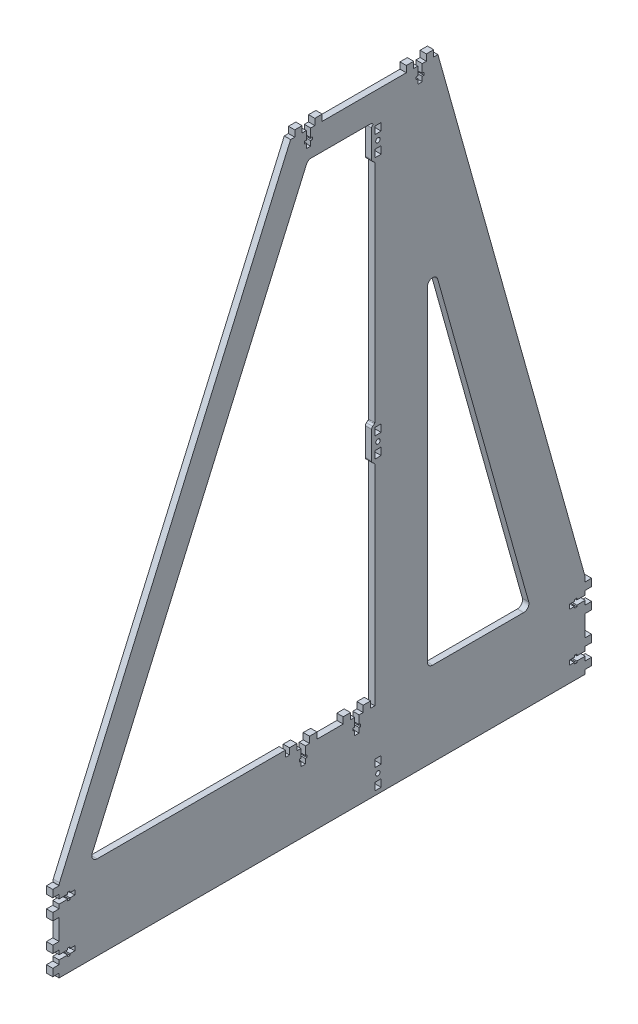
from build123d import *

# Parameters (mm, degrees)
EXTRUDE_869_DEPTH     = 6
SKETCH_2_W            = 7
SKETCH_2_H            = 6
EXTRUDE_2_DEPTH       = 6
CUT_EXTRUDE_1_DEPTH   = 7
SKETCH_21_W           = 7
SKETCH_21_H           = 6
EXTRUDE_21_DEPTH      = 6
CUT_EXTRUDE_11_DEPTH  = 7
SKETCH_22_W           = 7
SKETCH_22_H           = 6
EXTRUDE_22_DEPTH      = 6
SKETCH_23_W           = 7
SKETCH_23_H           = 6
EXTRUDE_23_DEPTH      = 6
SKETCH_24_W           = 7
SKETCH_24_H           = 6
EXTRUDE_24_DEPTH      = 6
CUT_EXTRUDE_14_DEPTH  = 7
SKETCH_25_W           = 7
SKETCH_25_H           = 6
EXTRUDE_25_DEPTH      = 6
CUT_EXTRUDE_15_DEPTH  = 7
SKETCH_26_W           = 7
SKETCH_26_H           = 6
EXTRUDE_26_DEPTH      = 6
SKETCH_27_W           = 7
SKETCH_27_H           = 6
EXTRUDE_27_DEPTH      = 6
SKETCH_28_W           = 7
SKETCH_28_H           = 6
EXTRUDE_28_DEPTH      = 6
CUT_EXTRUDE_18_DEPTH  = 7
SKETCH_29_W           = 7
SKETCH_29_H           = 6
EXTRUDE_29_DEPTH      = 6
CUT_EXTRUDE_19_DEPTH  = 7
SKETCH_210_W          = 7
SKETCH_210_H          = 6
EXTRUDE_210_DEPTH     = 6
SKETCH_211_W          = 7
SKETCH_211_H          = 6
EXTRUDE_211_DEPTH     = 6
SKETCH_312_R          = 2.1
SKETCH_312_W          = 7
SKETCH_312_H          = 6
CUT_EXTRUDE_112_DEPTH = 7
EXTRUDE_212_DEPTH     = 6
SKETCH_313_R          = 2.1
SKETCH_313_W          = 7
SKETCH_313_H          = 6
CUT_EXTRUDE_113_DEPTH = 7
EXTRUDE_213_DEPTH     = 6
EXTRUDE_214_DEPTH     = 6
SKETCH_315_R          = 2.1
SKETCH_315_W          = 7
SKETCH_315_H          = 6
CUT_EXTRUDE_115_DEPTH = 7
EXTRUDE_215_DEPTH     = 6
SKETCH_216_W          = 7
SKETCH_216_H          = 6
EXTRUDE_216_DEPTH     = 6
CUT_EXTRUDE_118_DEPTH = 7
SKETCH_218_W          = 7
SKETCH_218_H          = 6
EXTRUDE_219_DEPTH     = 6
CUT_EXTRUDE_121_DEPTH = 7


with BuildPart() as part:
    # Sketch 860 → Extrude 869 (new body)
    with BuildSketch(Plane(origin=(0, 0, 0), x_dir=(0, 0, -1), z_dir=(1, 0, 0))):
        with BuildLine():
            Line((-623.889101777, -244.379195599), (-123.889101777, -244.379195599))
            Line((-123.889101777, -244.379195599), (-123.889101777, -165.065988436))
            ThreePointArc((-123.889101777, -165.065988436), (-123.935613083, -164.385584326), (-124.074281679, -163.717838809))
            Line((-124.074281679, -163.717838809), (-263.889101777, 335.620804401))
            Line((-263.889101777, 335.620804401), (-313.803205915, 335.620804401))
            Line((-313.803205915, 335.620804401), (-403.889101777, 335.620804401))
            Line((-403.889101777, 335.620804401), (-623.469708885, -166.155300097))
            ThreePointArc((-623.469708885, -166.155300097), (-623.783130564, -167.135850443), (-623.889101777, -168.159804657))
            Line((-623.889101777, -168.159804657), (-623.889101777, -244.379195599))
        make_face()
        with BuildLine():
            Line((-323.889101777, 305.620804401), (-323.889101777, -164.379195599))
            Line((-323.889101777, -164.379195599), (-323.889101777, -170.379195599))
            Line((-323.889101777, -170.379195599), (-408.878708178, -170.379195599))
            Line((-408.878708178, -170.379195599), (-408.878708178, -164.379195599))
            Line((-408.878708178, -164.379195599), (-587.757688941, -164.379195599))
            ThreePointArc((-587.757688941, -164.379195599), (-591.942334851, -162.115751574), (-592.338296048, -157.37469104))
            Line((-592.338296048, -157.37469104), (-388.851160272, 307.62530896))
            ThreePointArc((-388.851160272, 307.62530896), (-387.007109139, 309.805450311), (-384.270553165, 310.620804401))
            Line((-384.270553165, 310.620804401), (-328.889101777, 310.620804401))
            ThreePointArc((-328.889101777, 310.620804401), (-325.353567872, 309.156338307), (-323.889101777, 305.620804401))
        make_face(mode=Mode.SUBTRACT)
        with BuildLine():
            Line((-268.889101777, -164.379195599), (-182.404423715, -164.379195599))
            ThreePointArc((-182.404423715, -164.379195599), (-178.420659908, -162.400722685), (-177.589603616, -158.031045972))
            Line((-177.589603616, -158.031045972), (-264.074281679, 150.842804252))
            ThreePointArc((-264.074281679, 150.842804252), (-269.569505888, 154.448143319), (-273.889101777, 149.494654625))
            Line((-273.889101777, 149.494654625), (-273.889101777, -159.379195599))
            ThreePointArc((-273.889101777, -159.379195599), (-272.424635683, -162.914729505), (-268.889101777, -164.379195599))
        make_face(mode=Mode.SUBTRACT)
    extrude(amount=EXTRUDE_869_DEPTH)

    # Эскиз2 → Бобышка-Вытянуть2 (add)
    with BuildSketch(Plane(origin=(6, 285.620804401, 386.889101777), x_dir=(0, 0, -1), z_dir=(1, 0, 0))):
        with Locations((-9.531849908, 53)):
            Rectangle(SKETCH_2_W, SKETCH_2_H)
        with Locations((9.531849908, 53)):
            Rectangle(SKETCH_2_W, SKETCH_2_H)
    extrude(amount=-EXTRUDE_2_DEPTH)

    # Эскиз3 → Вырез-Вытянуть1 (cut, through all)
    with BuildSketch(Plane(origin=(6, 285.620804401, 386.889101777), x_dir=(0, 0, -1), z_dir=(1, 0, 0))):
        Polygon((-2.1, 42), (-3.6, 42), (-3.6, 39.6), (-2.1, 39.6), (-2.1, 35), (2.1, 35), (2.1, 39.6), (3.6, 39.6), (3.6, 42), (2.1, 42), (2.1, 50), (-2.1, 50), align=None)
    extrude(amount=-CUT_EXTRUDE_1_DEPTH, mode=Mode.SUBTRACT)

    # Эскиз21 → Бобышка-Вытянуть21 (add)
    with BuildSketch(Plane(origin=(6, 285.620804401, 280.889101778), x_dir=(0, 0, -1), z_dir=(1, 0, 0))):
        with Locations((-9.531849908, 53)):
            Rectangle(SKETCH_21_W, SKETCH_21_H)
        with Locations((9.531849908, 53)):
            Rectangle(SKETCH_21_W, SKETCH_21_H)
    extrude(amount=-EXTRUDE_21_DEPTH)

    # Эскиз31 → Вырез-Вытянуть11 (cut, through all)
    with BuildSketch(Plane(origin=(6, 285.620804401, 280.889101778), x_dir=(0, 0, -1), z_dir=(1, 0, 0))):
        Polygon((-2.1, 42), (-3.6, 42), (-3.6, 39.6), (-2.1, 39.6), (-2.1, 35), (2.1, 35), (2.1, 39.6), (3.6, 39.6), (3.6, 42), (2.1, 42), (2.1, 50), (-2.1, 50), align=None)
    extrude(amount=-CUT_EXTRUDE_11_DEPTH, mode=Mode.SUBTRACT)

    # Эскиз22 → Бобышка-Вытянуть22 (add)
    with BuildSketch(Plane(origin=(0, 285.620804401, 386.889101777), x_dir=(0, 0, 1), z_dir=(-1, 0, 0))):
        with Locations((-9.531849908, 53)):
            Rectangle(SKETCH_22_W, SKETCH_22_H)
        with Locations((9.531849908, 53)):
            Rectangle(SKETCH_22_W, SKETCH_22_H)
    extrude(amount=-EXTRUDE_22_DEPTH)

    # Эскиз23 → Бобышка-Вытянуть23 (add)
    with BuildSketch(Plane(origin=(0, 285.620804401, 280.889101777), x_dir=(0, 0, 1), z_dir=(-1, 0, 0))):
        with Locations((-9.531849908, 53)):
            Rectangle(SKETCH_23_W, SKETCH_23_H)
        with Locations((9.531849908, 53)):
            Rectangle(SKETCH_23_W, SKETCH_23_H)
    extrude(amount=-EXTRUDE_23_DEPTH)

    # Эскиз24 → Бобышка-Вытянуть24 (add)
    with BuildSketch(Plane(origin=(0, -181.461538462, 573.889101777), x_dir=(0, -1, 0), z_dir=(-1, 0, 0))):
        with Locations((-9.531849908, 53)):
            Rectangle(SKETCH_24_W, SKETCH_24_H)
        with Locations((9.531849908, 53)):
            Rectangle(SKETCH_24_W, SKETCH_24_H)
    extrude(amount=-EXTRUDE_24_DEPTH)

    # Эскиз34 → Вырез-Вытянуть14 (cut, through all)
    with BuildSketch(Plane(origin=(0, -181.461538462, 573.889101777), x_dir=(0, -1, 0), z_dir=(-1, 0, 0))):
        Polygon((-2.1, 42), (-3.6, 42), (-3.6, 39.6), (-2.1, 39.6), (-2.1, 35), (2.1, 35), (2.1, 39.6), (3.6, 39.6), (3.6, 42), (2.1, 42), (2.1, 50), (-2.1, 50), align=None)
    extrude(amount=-CUT_EXTRUDE_14_DEPTH, mode=Mode.SUBTRACT)

    # Эскиз25 → Бобышка-Вытянуть25 (add)
    with BuildSketch(Plane(origin=(0, -227.379195599, 573.889101777), x_dir=(0, -1, 0), z_dir=(-1, 0, 0))):
        with Locations((-9.531849908, 53)):
            Rectangle(SKETCH_25_W, SKETCH_25_H)
        with Locations((9.531849908, 53)):
            Rectangle(SKETCH_25_W, SKETCH_25_H)
    extrude(amount=-EXTRUDE_25_DEPTH)

    # Эскиз35 → Вырез-Вытянуть15 (cut, through all)
    with BuildSketch(Plane(origin=(0, -227.379195599, 573.889101777), x_dir=(0, -1, 0), z_dir=(-1, 0, 0))):
        Polygon((-2.1, 42), (-3.6, 42), (-3.6, 39.6), (-2.1, 39.6), (-2.1, 35), (2.1, 35), (2.1, 39.6), (3.6, 39.6), (3.6, 42), (2.1, 42), (2.1, 50), (-2.1, 50), align=None)
    extrude(amount=-CUT_EXTRUDE_15_DEPTH, mode=Mode.SUBTRACT)

    # Эскиз26 → Бобышка-Вытянуть26 (add)
    with BuildSketch(Plane(origin=(6, -181.461538462, 573.889101777), x_dir=(0, 1, 0), z_dir=(1, 0, 0))):
        with Locations((-9.531849908, 53)):
            Rectangle(SKETCH_26_W, SKETCH_26_H)
        with Locations((9.531849908, 53)):
            Rectangle(SKETCH_26_W, SKETCH_26_H)
    extrude(amount=-EXTRUDE_26_DEPTH)

    # Эскиз27 → Бобышка-Вытянуть27 (add)
    with BuildSketch(Plane(origin=(6, -227.379195599, 573.889101777), x_dir=(0, 1, 0), z_dir=(1, 0, 0))):
        with Locations((-9.531849908, 53)):
            Rectangle(SKETCH_27_W, SKETCH_27_H)
        with Locations((9.531849908, 53)):
            Rectangle(SKETCH_27_W, SKETCH_27_H)
    extrude(amount=-EXTRUDE_27_DEPTH)

    # Эскиз28 → Бобышка-Вытянуть28 (add)
    with BuildSketch(Plane(origin=(6, -181.379195599, 173.889101777), x_dir=(0, -1, 0), z_dir=(1, 0, 0))):
        with Locations((-9.531849908, 53)):
            Rectangle(SKETCH_28_W, SKETCH_28_H)
        with Locations((9.531849908, 53)):
            Rectangle(SKETCH_28_W, SKETCH_28_H)
    extrude(amount=-EXTRUDE_28_DEPTH)

    # Эскиз38 → Вырез-Вытянуть18 (cut, through all)
    with BuildSketch(Plane(origin=(6, -181.379195599, 173.889101777), x_dir=(0, -1, 0), z_dir=(1, 0, 0))):
        Polygon((-2.1, 42), (-3.6, 42), (-3.6, 39.6), (-2.1, 39.6), (-2.1, 35), (2.1, 35), (2.1, 39.6), (3.6, 39.6), (3.6, 42), (2.1, 42), (2.1, 50), (-2.1, 50), align=None)
    extrude(amount=-CUT_EXTRUDE_18_DEPTH, mode=Mode.SUBTRACT)

    # Эскиз29 → Бобышка-Вытянуть29 (add)
    with BuildSketch(Plane(origin=(6, -227.379195599, 173.889101777), x_dir=(0, -1, 0), z_dir=(1, 0, 0))):
        with Locations((-9.531849908, 53)):
            Rectangle(SKETCH_29_W, SKETCH_29_H)
        with Locations((9.531849908, 53)):
            Rectangle(SKETCH_29_W, SKETCH_29_H)
    extrude(amount=-EXTRUDE_29_DEPTH)

    # Эскиз39 → Вырез-Вытянуть19 (cut, through all)
    with BuildSketch(Plane(origin=(6, -227.379195599, 173.889101777), x_dir=(0, -1, 0), z_dir=(1, 0, 0))):
        Polygon((-2.1, 42), (-3.6, 42), (-3.6, 39.6), (-2.1, 39.6), (-2.1, 35), (2.1, 35), (2.1, 39.6), (3.6, 39.6), (3.6, 42), (2.1, 42), (2.1, 50), (-2.1, 50), align=None)
    extrude(amount=-CUT_EXTRUDE_19_DEPTH, mode=Mode.SUBTRACT)

    # Эскиз210 → Бобышка-Вытянуть210 (add)
    with BuildSketch(Plane(origin=(0, -181.379195599, 173.889101777), x_dir=(0, 1, 0), z_dir=(-1, 0, 0))):
        with Locations((-9.531849908, 53)):
            Rectangle(SKETCH_210_W, SKETCH_210_H)
        with Locations((9.531849908, 53)):
            Rectangle(SKETCH_210_W, SKETCH_210_H)
    extrude(amount=-EXTRUDE_210_DEPTH)

    # Эскиз211 → Бобышка-Вытянуть211 (add)
    with BuildSketch(Plane(origin=(0, -227.379195599, 173.889101777), x_dir=(0, 1, 0), z_dir=(-1, 0, 0))):
        with Locations((-9.531849908, 53)):
            Rectangle(SKETCH_211_W, SKETCH_211_H)
        with Locations((9.531849908, 53)):
            Rectangle(SKETCH_211_W, SKETCH_211_H)
    extrude(amount=-EXTRUDE_211_DEPTH)

    # Эскиз312 → Вырез-Вытянуть112 (cut, through all)
    with BuildSketch(Plane(origin=(6, -227.379195599, 273.889101777), x_dir=(0, 1, 0), z_dir=(1, 0, 0))):
        with Locations((0, 47)):
            Circle(SKETCH_312_R)
        with Locations((9.531849908, 47)):
            Rectangle(SKETCH_312_W, SKETCH_312_H)
        with Locations((-9.531849908, 47)):
            Rectangle(SKETCH_312_W, SKETCH_312_H)
    extrude(amount=-CUT_EXTRUDE_112_DEPTH, mode=Mode.SUBTRACT)

    # Эскиз212 → Бобышка-Вытянуть212 (add)
    with BuildSketch(Plane(origin=(0, 45.620804401, 273.889101777), x_dir=(0, 1, 0), z_dir=(1, 0, 0))):
        with BuildLine():
            Line((13, 53), (-13, 53))
            ThreePointArc((-13, 53), (-14.118033989, 52.736067977), (-15, 52))
            Line((-15, 52), (-16.2, 50.4))
            ThreePointArc((-16.2, 50.4), (-16.552786405, 50.105572809), (-17, 50))
            Line((-17, 50), (17, 50))
            ThreePointArc((17, 50), (16.552786405, 50.105572809), (16.2, 50.4))
            Line((16.2, 50.4), (15, 52))
            ThreePointArc((15, 52), (14.118033989, 52.736067977), (13, 53))
        make_face()
    extrude(amount=EXTRUDE_212_DEPTH)

    # Эскиз313 → Вырез-Вытянуть113 (cut, through all)
    with BuildSketch(Plane(origin=(6, 45.620804401, 273.889101777), x_dir=(0, 1, 0), z_dir=(1, 0, 0))):
        with Locations((0, 47)):
            Circle(SKETCH_313_R)
        with Locations((9.531849908, 47)):
            Rectangle(SKETCH_313_W, SKETCH_313_H)
        with Locations((-9.531849908, 47)):
            Rectangle(SKETCH_313_W, SKETCH_313_H)
    extrude(amount=-CUT_EXTRUDE_113_DEPTH, mode=Mode.SUBTRACT)

    # Эскиз213 → Бобышка-Вытянуть213 (add)
    with BuildSketch(Plane(origin=(6, 45.620804401, 273.889101777), x_dir=(0, -1, 0), z_dir=(-1, 0, 0))):
        with BuildLine():
            Line((-13, 53), (13, 53))
            ThreePointArc((13, 53), (14.118033989, 52.736067977), (15, 52))
            Line((15, 52), (16.2, 50.4))
            ThreePointArc((16.2, 50.4), (16.552786405, 50.105572809), (17, 50))
            Line((17, 50), (-17, 50))
            ThreePointArc((-17, 50), (-16.552786405, 50.105572809), (-16.2, 50.4))
            Line((-16.2, 50.4), (-15, 52))
            ThreePointArc((-15, 52), (-14.118033989, 52.736067977), (-13, 53))
        make_face()
    extrude(amount=EXTRUDE_213_DEPTH)

    # Эскиз214 → Бобышка-Вытянуть214 (add)
    with BuildSketch(Plane(origin=(6, 293.620804401, 273.889101777), x_dir=(0, -1, 0), z_dir=(-1, 0, 0))):
        with BuildLine():
            Line((13, 53), (-13, 53))
            ThreePointArc((-13, 53), (-14.118033989, 52.736067977), (-15, 52))
            Line((-15, 52), (-16.2, 50.4))
            ThreePointArc((-16.2, 50.4), (-16.552786405, 50.105572809), (-17, 50))
            Line((-17, 50), (17, 50))
            ThreePointArc((17, 50), (16.552786405, 50.105572809), (16.2, 50.4))
            Line((16.2, 50.4), (15, 52))
            ThreePointArc((15, 52), (14.118033989, 52.736067977), (13, 53))
        make_face()
    extrude(amount=EXTRUDE_214_DEPTH)

    # Эскиз315 → Вырез-Вытянуть115 (cut, through all)
    with BuildSketch(Plane(origin=(0, 293.620804401, 273.889101777), x_dir=(0, -1, 0), z_dir=(-1, 0, 0))):
        with Locations((0, 47)):
            Circle(SKETCH_315_R)
        with Locations((9.531849908, 47)):
            Rectangle(SKETCH_315_W, SKETCH_315_H)
        with Locations((-9.531849908, 47)):
            Rectangle(SKETCH_315_W, SKETCH_315_H)
    extrude(amount=-CUT_EXTRUDE_115_DEPTH, mode=Mode.SUBTRACT)

    # Эскиз215 → Бобышка-Вытянуть215 (add)
    with BuildSketch(Plane(origin=(0, 293.620804401, 273.889101777), x_dir=(0, 1, 0), z_dir=(1, 0, 0))):
        with BuildLine():
            Line((-13, 53), (13, 53))
            ThreePointArc((13, 53), (14.118033989, 52.736067977), (15, 52))
            Line((15, 52), (16.2, 50.4))
            ThreePointArc((16.2, 50.4), (16.552786405, 50.105572809), (17, 50))
            Line((17, 50), (-17, 50))
            ThreePointArc((-17, 50), (-16.552786405, 50.105572809), (-16.2, 50.4))
            Line((-16.2, 50.4), (-15, 52))
            ThreePointArc((-15, 52), (-14.118033989, 52.736067977), (-13, 53))
        make_face()
    extrude(amount=EXTRUDE_215_DEPTH)

    # Эскиз216 → Бобышка-Вытянуть216 (add)
    with BuildSketch(Plane(origin=(6, -220.379195599, 340.889101777), x_dir=(0, 0, -1), z_dir=(1, 0, 0))):
        with Locations((-9.531849908, 53)):
            Rectangle(SKETCH_216_W, SKETCH_216_H)
        with Locations((9.531849908, 53)):
            Rectangle(SKETCH_216_W, SKETCH_216_H)
    extrude(amount=-EXTRUDE_216_DEPTH)

    # Эскиз318 → Вырез-Вытянуть118 (cut, through all)
    with BuildSketch(Plane(origin=(6, -220.379195599, 340.889101777), x_dir=(0, 0, -1), z_dir=(1, 0, 0))):
        Polygon((-2.1, 42), (-3.6, 42), (-3.6, 39.6), (-2.1, 39.6), (-2.1, 35), (2.1, 35), (2.1, 39.6), (3.6, 39.6), (3.6, 42), (2.1, 42), (2.1, 50), (-2.1, 50), align=None)
    extrude(amount=-CUT_EXTRUDE_118_DEPTH, mode=Mode.SUBTRACT)

    # Эскиз218 → Бобышка-Вытянуть219 (add)
    with BuildSketch(Plane(origin=(6, -220.379195599, 391.889101778), x_dir=(0, 0, -1), z_dir=(1, 0, 0))):
        with Locations((-9.531849908, 53)):
            Rectangle(SKETCH_218_W, SKETCH_218_H)
        with Locations((9.531849908, 53)):
            Rectangle(SKETCH_218_W, SKETCH_218_H)
    extrude(amount=-EXTRUDE_219_DEPTH)

    # Эскиз321 → Вырез-Вытянуть121 (cut, through all)
    with BuildSketch(Plane(origin=(6, -220.379195599, 391.889101778), x_dir=(0, 0, -1), z_dir=(1, 0, 0))):
        Polygon((-2.1, 42), (-3.6, 42), (-3.6, 39.6), (-2.1, 39.6), (-2.1, 35), (2.1, 35), (2.1, 39.6), (3.6, 39.6), (3.6, 42), (2.1, 42), (2.1, 50), (-2.1, 50), align=None)
    extrude(amount=-CUT_EXTRUDE_121_DEPTH, mode=Mode.SUBTRACT)


solid = part.part
